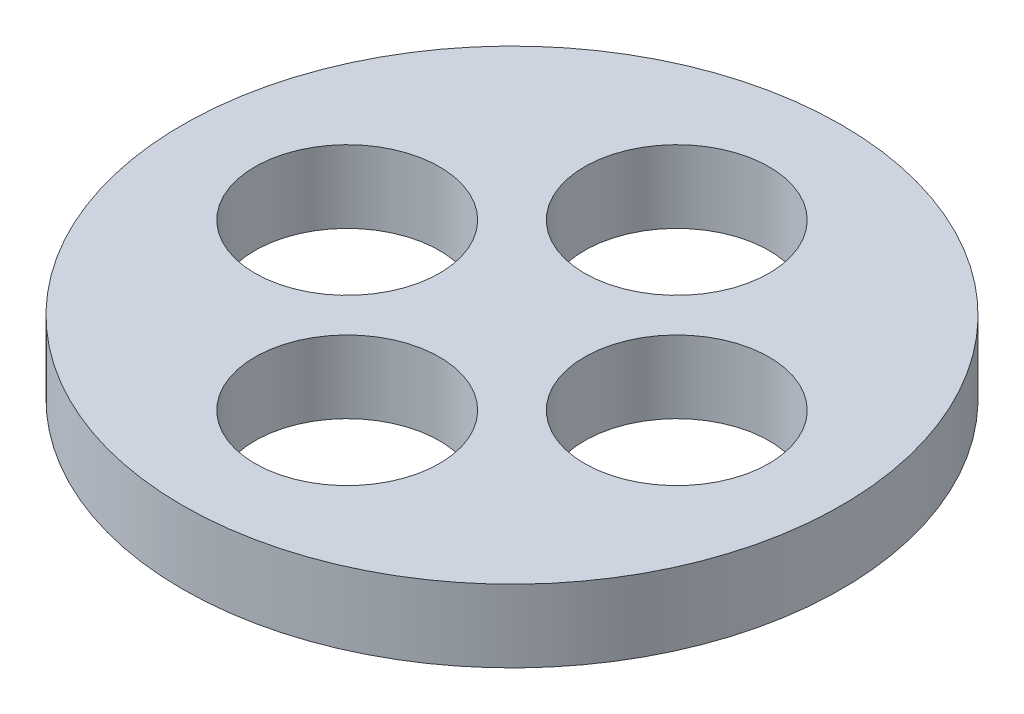
from build123d import *

# Parameters (mm, degrees)
SKETCH1_R           = 25
BOSS_EXTRUDE1_DEPTH = 5.5
SKETCH2_R           = 7
CUT_EXTRUDE1_DEPTH  = 5.5


with BuildPart() as part:
    # Sketch1 → Boss-Extrude1 (new body)
    with BuildSketch(Plane(origin=(0, 0, 0), x_dir=(1, 0, 0), z_dir=(0, 1, 0))):
        Circle(SKETCH1_R)
    extrude(amount=BOSS_EXTRUDE1_DEPTH)

    # Sketch2 → Cut-Extrude1 (cut)
    with BuildSketch(Plane(origin=(0, 5.5, 0), x_dir=(1, 0, 0), z_dir=(0, 1, 0))):
        with Locations((0, 12.5)):
            Circle(SKETCH2_R)
        with Locations((12.5, 0)):
            Circle(SKETCH2_R)
        with Locations((0, -12.5)):
            Circle(SKETCH2_R)
        with Locations((-12.5, 0)):
            Circle(SKETCH2_R)
    extrude(amount=-CUT_EXTRUDE1_DEPTH, mode=Mode.SUBTRACT)


solid = part.part
